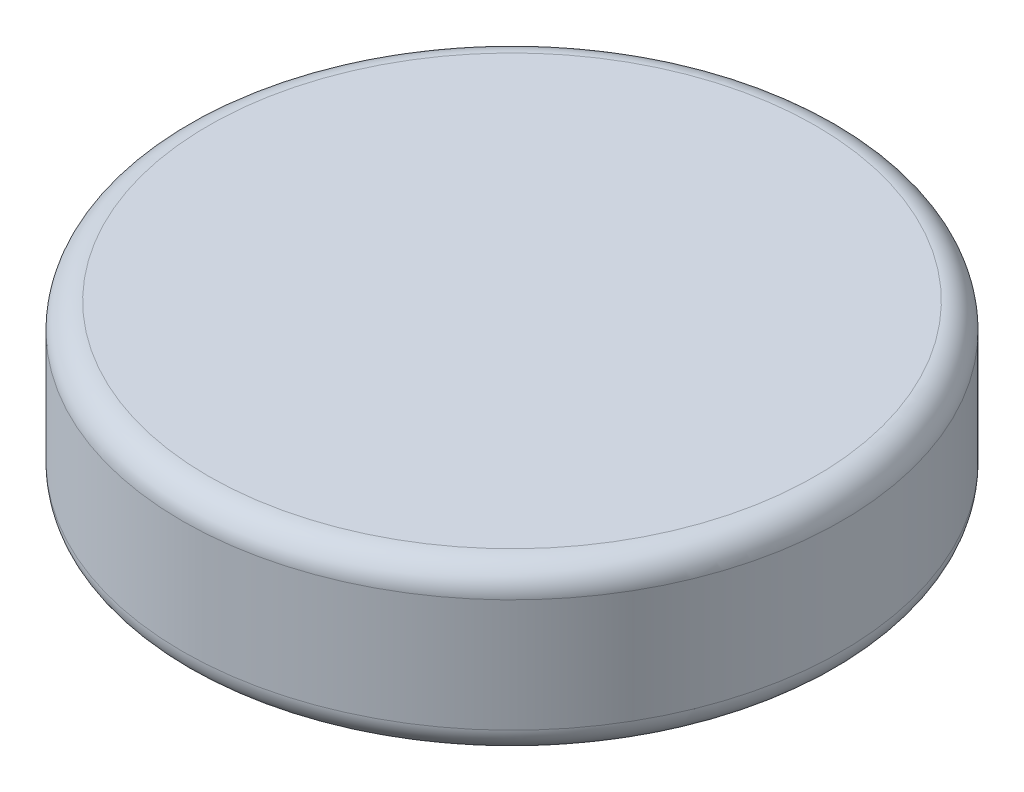
from build123d import *

# Parameters (mm, degrees)
SKETCH2_R           = 3.175
BOSS_EXTRUDE1_DEPTH = 1.5875
FILLET1_R           = 0.25


with BuildPart() as part:
    # Sketch2 → Boss-Extrude1 (new body)
    with BuildSketch(Plane(origin=(0, 0, 0), x_dir=(1, 0, 0), z_dir=(0, 1, 0))):
        Circle(SKETCH2_R)
    extrude(amount=BOSS_EXTRUDE1_DEPTH)

    # Fillet1
    fillet1_edges = [part.edges().sort_by_distance(p)[0] for p in [
        (-3.175, 0, 0),
        (-3.175, 1.5875, 0),
    ]]
    fillet(fillet1_edges, radius=FILLET1_R)


solid = part.part
